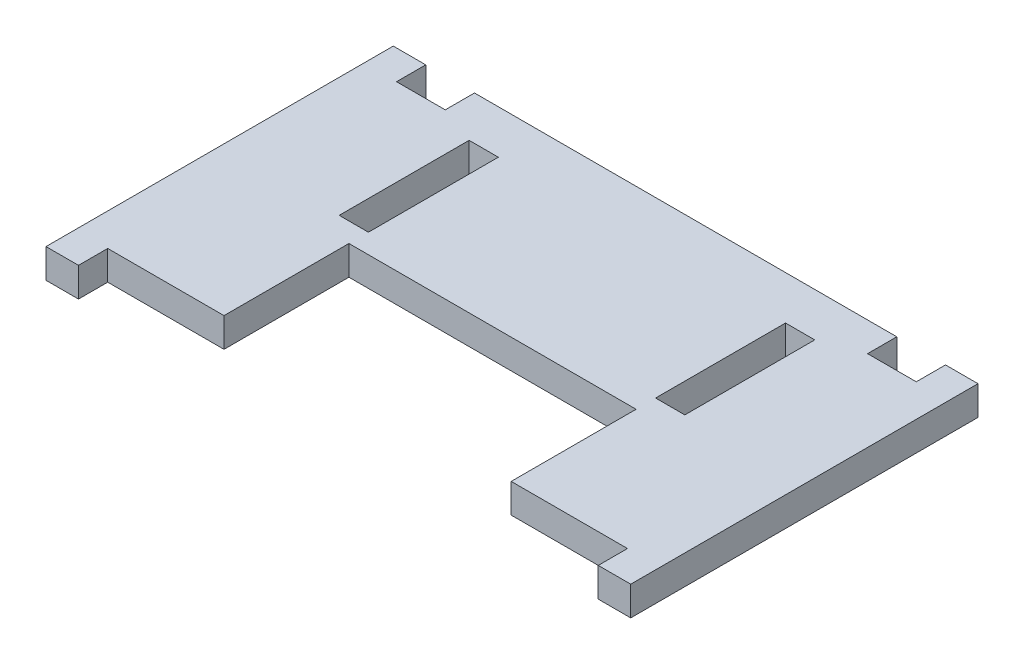
from build123d import *

# Parameters (mm, degrees)
SKETCH1_W           = 4.5
SKETCH1_H           = 20
BOSS_EXTRUDE1_DEPTH = 4.5
SKETCH2_W           = 44.2
SKETCH2_H           = 19.225
CUT_EXTRUDE1_DEPTH  = 5.5
SKETCH3_W           = 65
SKETCH3_H           = 4.5
BOSS_EXTRUDE2_DEPTH = 4.5


with BuildPart() as part:
    # Sketch1 → Boss-Extrude1 (new body)
    with BuildSketch(Plane(origin=(0, 0, 0), x_dir=(1, 0, 0), z_dir=(0, 1, 0))):
        Polygon((-40, -22.225), (-40, -26.725), (-45, -26.725), (-45, 26.725), (-40, 26.725), (-40, 22.225), (0, 22.225), (0, -22.225), align=None)
        with Locations((-24.35, 10)):
            Rectangle(SKETCH1_W, SKETCH1_H, mode=Mode.SUBTRACT)
    boss_extrude1 = extrude(amount=BOSS_EXTRUDE1_DEPTH)

    # Mirror1: Boss-Extrude1 across plane
    add(boss_extrude1.mirror(Plane(origin=(0, 4.5, -22.225), x_dir=(0, 0, 1), z_dir=(-1, 0, 0))))

    # Sketch2 → Cut-Extrude1 (cut, through all)
    with BuildSketch(Plane(origin=(0, 4.5, 0), x_dir=(1, 0, 0), z_dir=(0, 1, 0))):
        with Locations((0, -12.6125)):
            Rectangle(SKETCH2_W, SKETCH2_H)
    extrude(amount=-CUT_EXTRUDE1_DEPTH, mode=Mode.SUBTRACT)

    # Sketch3 → Boss-Extrude2 (add)
    with BuildSketch(Plane(origin=(0, 4.5, 0), x_dir=(1, 0, 0), z_dir=(0, 1, 0))):
        with Locations((0, 24.475)):
            Rectangle(SKETCH3_W, SKETCH3_H)
    extrude(amount=-BOSS_EXTRUDE2_DEPTH)


solid = part.part
